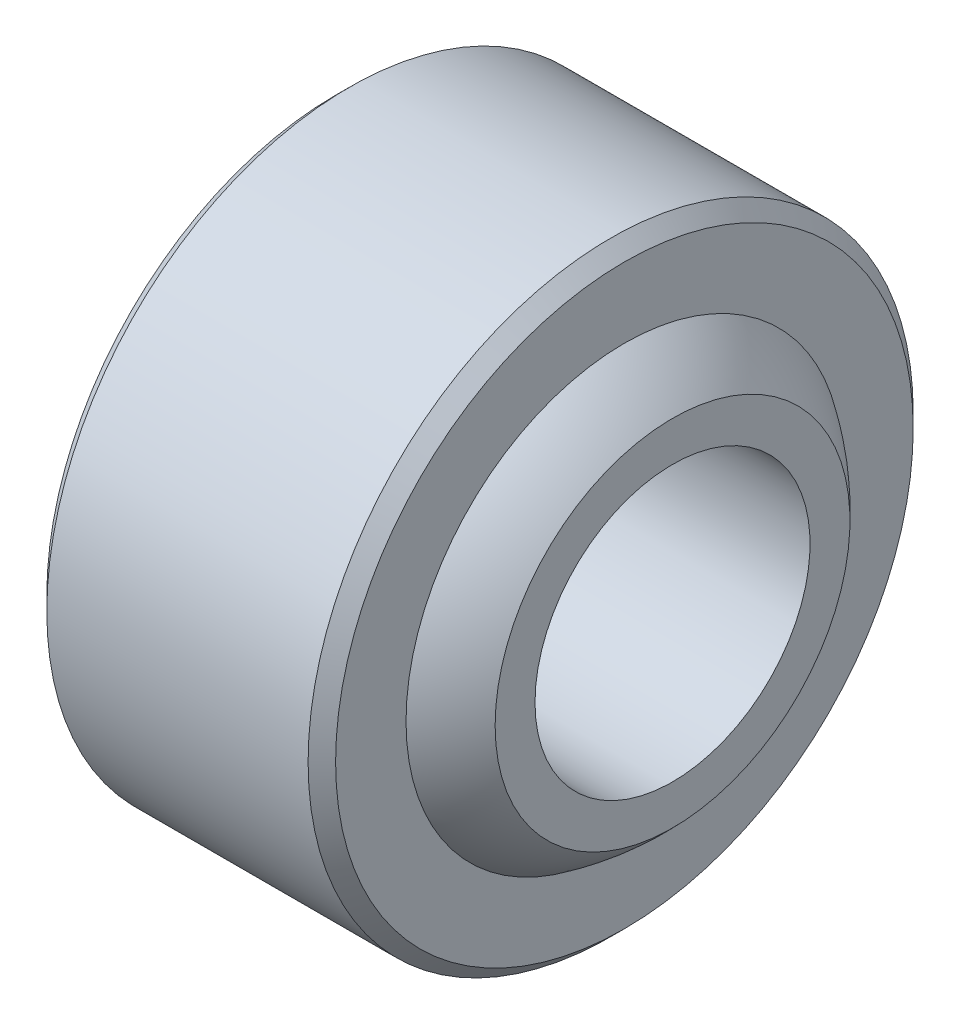
from build123d import *

# Parameters (mm, degrees)
SFAZOWANIE1_SIZE = 0.5


with BuildPart() as part:
    # Szkic1 → Obrót1 (revolve)
    with BuildSketch(Plane.XY):
        with BuildLine():
            Line((-7, 0), (7, 0))
            Line((7, 0), (7, 1.45))
            ThreePointArc((7, 1.45), (6.170128128, 2.247897549), (5.25, 2.939773297))
            Line((5.25, 2.939773297), (5.25, 6))
            Line((5.25, 6), (-5.25, 6))
            Line((-5.25, 6), (-5.25, 2.939773297))
            ThreePointArc((-5.25, 2.939773297), (-6.170128128, 2.247897549), (-7, 1.45))
            Line((-7, 1.45), (-7, 0))
        make_face()
    revolve(axis=Axis((-7.6504069, -5, 0), (1, 0, 0)))

    # Sfazowanie1
    sfazowanie1_edges = [part.edges().sort_by_distance(p)[0] for p in [
        (-5.25, -16, 0),
        (5.25, -16, 0),
    ]]
    chamfer(sfazowanie1_edges, length=SFAZOWANIE1_SIZE)


solid = part.part
